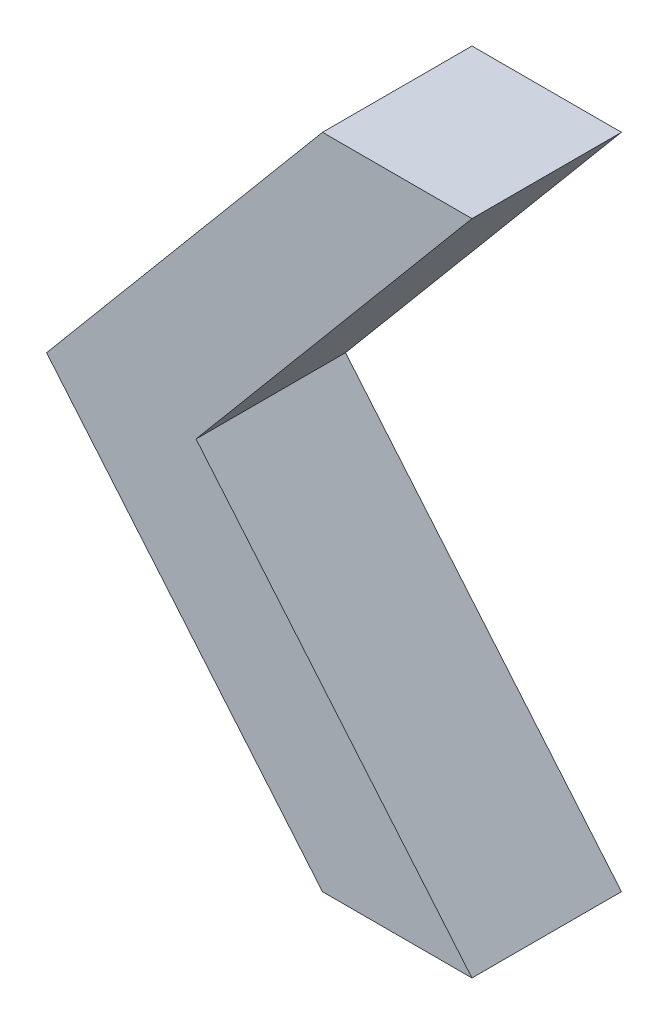
from build123d import *

# Parameters (mm, degrees)
BOSS_EXTRUDE1_DEPTH = 12.5


with BuildPart() as part:
    # Sketch1 → Boss-Extrude1 (new body)
    with BuildSketch(Plane.XY):
        Polygon((0, 0), (-23.075239857, -27.5), (0, -55), (12.5, -55), (-10.575239857, -27.5), (12.5, 0), align=None)
    extrude(amount=BOSS_EXTRUDE1_DEPTH)


solid = part.part
